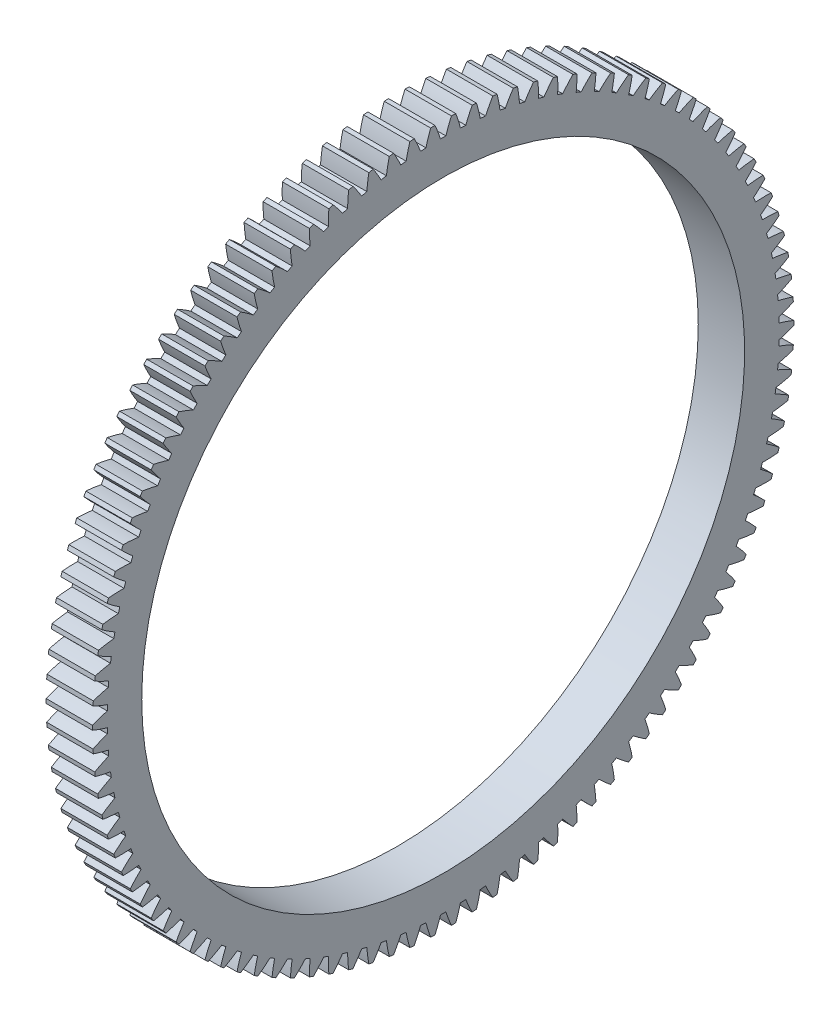
from build123d import *

# Parameters (mm, degrees)
BASPROSKE_W     = 5
BASPROSKE_H     = 37.8
TOOTHCUT_DEPTH  = 54.69059508
TEETHCUTS_COUNT = 106
TEETHCUTS_ANGLE = 356.603773585
BORSKE_R        = 32.5
BORE_DEPTH      = 50.0000508


with BuildPart() as part:
    # BasProSke → Base-Revolve (revolve)
    with BuildSketch(Plane(origin=(0, 0, 0), x_dir=(1, 0, 0), z_dir=(0, 1, 0)), mode=Mode.PRIVATE) as base_revolve_sk:
        with Locations((2.5, 18.9)):
            Rectangle(BASPROSKE_W, BASPROSKE_H)
    revolve(base_revolve_sk.sketch.rotate(Axis((-10, 0, 0), (1, 0, 0)), 180), axis=Axis((-10, 0, 0), (1, 0, 0)))

    # TooCutSke → ToothCut (cut, through all)
    with BuildSketch(Plane(origin=(0, 0, 0), x_dir=(0, 0, -1), z_dir=(1, 0, 0))):
        with BuildLine():
            ThreePointArc((0.289925111, 36.222839748), (0, 36.224), (-0.289925111, 36.222839748))
            ThreePointArc((-0.289925111, 36.222839748), (-0.570978508, 37.027523753), (-0.897767291, 37.814744466))
            ThreePointArc((-0.897767291, 37.814744466), (0, 37.8254), (0.897767291, 37.814744466))
            ThreePointArc((0.897767291, 37.814744466), (0.570978508, 37.027523753), (0.289925111, 36.222839748))
        make_face()
    toothcut = extrude(amount=TOOTHCUT_DEPTH, mode=Mode.SUBTRACT)

    # TeethCuts: ToothCut ×106 about axis
    teethcuts_axis = Axis((-10, 0, 0), (1, 0, 0))
    for i in range(1, TEETHCUTS_COUNT):
        add(toothcut.rotate(teethcuts_axis, i * TEETHCUTS_ANGLE / (TEETHCUTS_COUNT - 1)), mode=Mode.SUBTRACT)

    # BorSke → Bore (cut, symmetric)
    with BuildSketch(Plane(origin=(0, 0, 0), x_dir=(0, 0, -1), z_dir=(1, 0, 0))):
        with Locations(Location((0, 0, 0), (0, 0, 180))):
            Circle(BORSKE_R)
    extrude(amount=BORE_DEPTH, both=True, mode=Mode.SUBTRACT)


solid = part.part
